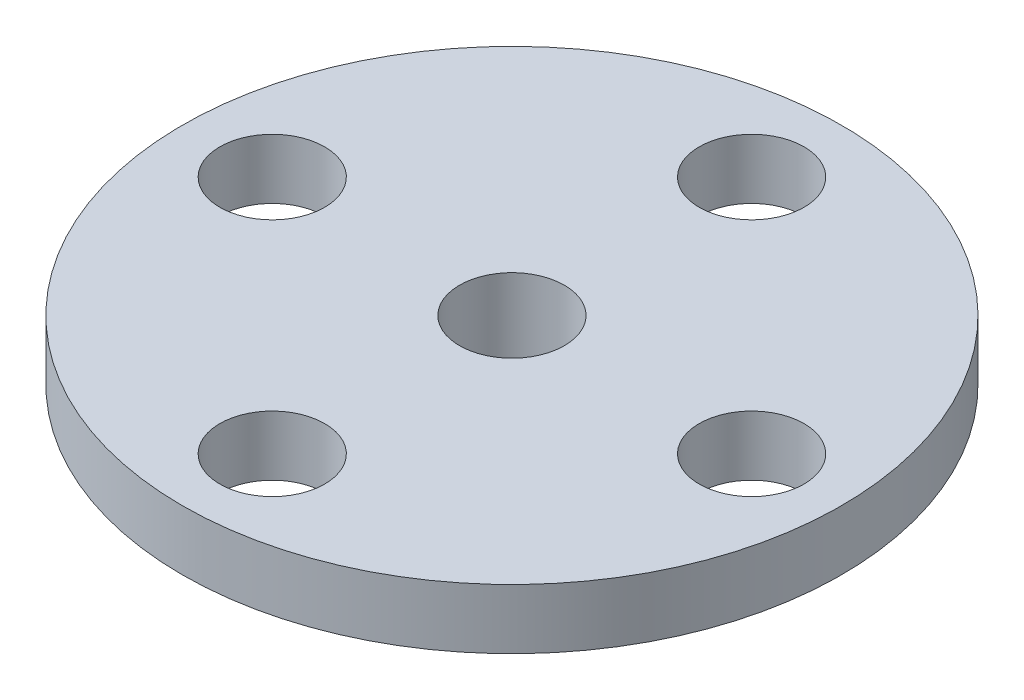
from build123d import *

# Parameters (mm, degrees)
SKETCH1_W                                        = 11
SKETCH1_H                                        = 2
SKETCH2_R                                        = 4.4
BOSS_EXTRUDE1_DEPTH                              = 4.2
F_3_5_3_5_DIAMETER_HOLE1_D                       = 3.5
F_3_5_3_5_DIAMETER_HOLE1_DEPTH                   = 2
CBORE_FOR_M3_HEX_HEAD_MACHINE_SCREW1_D           = 3.5
CBORE_FOR_M3_HEX_HEAD_MACHINE_SCREW1_DEPTH       = 6.2
CBORE_FOR_M3_HEX_HEAD_MACHINE_SCREW1_CBORE_D     = 5.7
CBORE_FOR_M3_HEX_HEAD_MACHINE_SCREW1_CBORE_DEPTH = 3


with BuildPart() as part:
    # Sketch1 → Revolve1 (revolve)
    with BuildSketch(Plane(origin=(0, 0, 0), x_dir=(-1, 0, 0), z_dir=(0, 0, -1))):
        with Locations((-5.5, 1)):
            Rectangle(SKETCH1_W, SKETCH1_H)
    revolve(axis=Axis((0, 0, 0), (0, 1, 0)))

    # Sketch2 → Boss-Extrude1 (add)
    with BuildSketch(Plane.XZ):
        Circle(SKETCH2_R)
    extrude(amount=BOSS_EXTRUDE1_DEPTH)

    # Ø3.5 (3.5) Diameter Hole1
    with Locations(Plane(origin=(0, 0, 0), x_dir=(-1, 0, 0), z_dir=(0, -1, 0))):
        with Locations((-8, 0), (0, -8), (8, 0), (0, 8)):
            Hole(F_3_5_3_5_DIAMETER_HOLE1_D / 2, depth=F_3_5_3_5_DIAMETER_HOLE1_DEPTH)

    # CBORE for M3 Hex Head Machine Screw1
    with Locations(Plane(origin=(0, -4.2, 0), x_dir=(-1, 0, 0), z_dir=(0, -1, 0))):
        with Locations((0, 0)):
            CounterBoreHole(CBORE_FOR_M3_HEX_HEAD_MACHINE_SCREW1_D / 2, CBORE_FOR_M3_HEX_HEAD_MACHINE_SCREW1_CBORE_D / 2, CBORE_FOR_M3_HEX_HEAD_MACHINE_SCREW1_CBORE_DEPTH, depth=CBORE_FOR_M3_HEX_HEAD_MACHINE_SCREW1_DEPTH)


solid = part.part
